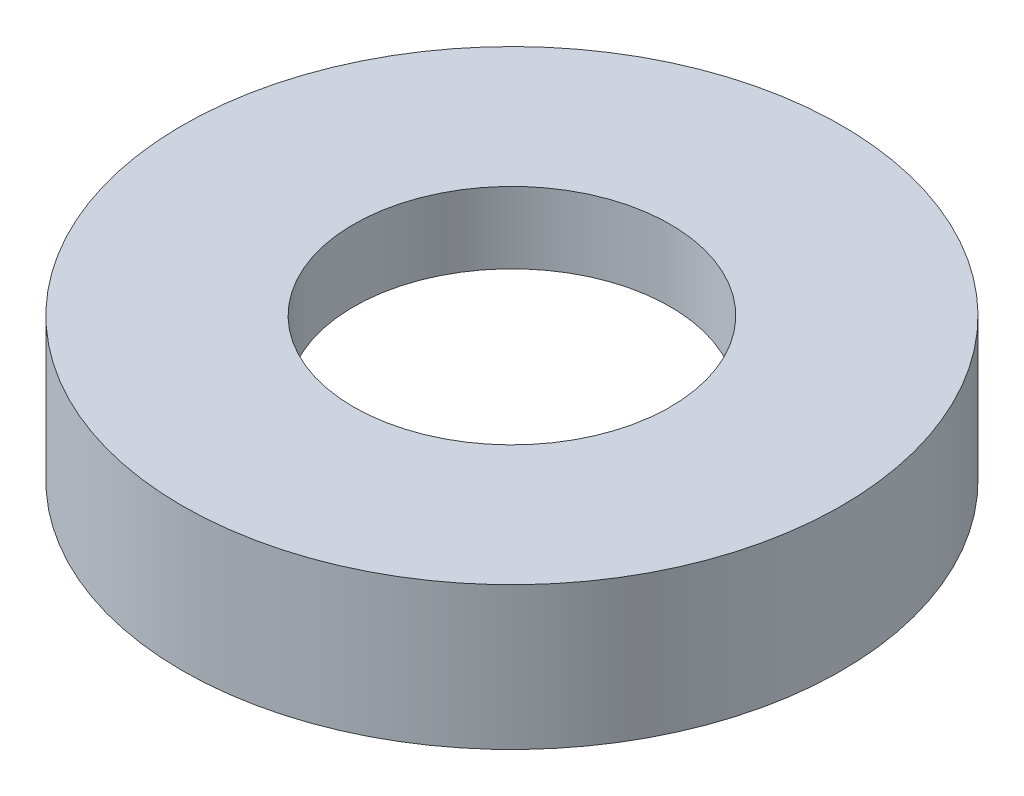
from build123d import *


with BuildPart() as part:
    # 草图1 → 旋转1 (revolve)
    with BuildSketch(Plane.XY, mode=Mode.PRIVATE) as revolve_1_sk:
        Polygon((23.5, 0), (23.5, 4.5), (24.1, 4.5), (24.1, 5.5), (12.2, 5.5), (12.2, 11), (25.4, 11), (25.4, 0), align=None)
    revolve(revolve_1_sk.sketch.rotate(Axis((0, 60.020820414, 0), (0, -1, 0)), 90), axis=Axis((0, 60.020820414, 0), (0, -1, 0)))  # turned: the seam where the file's is


solid = part.part
